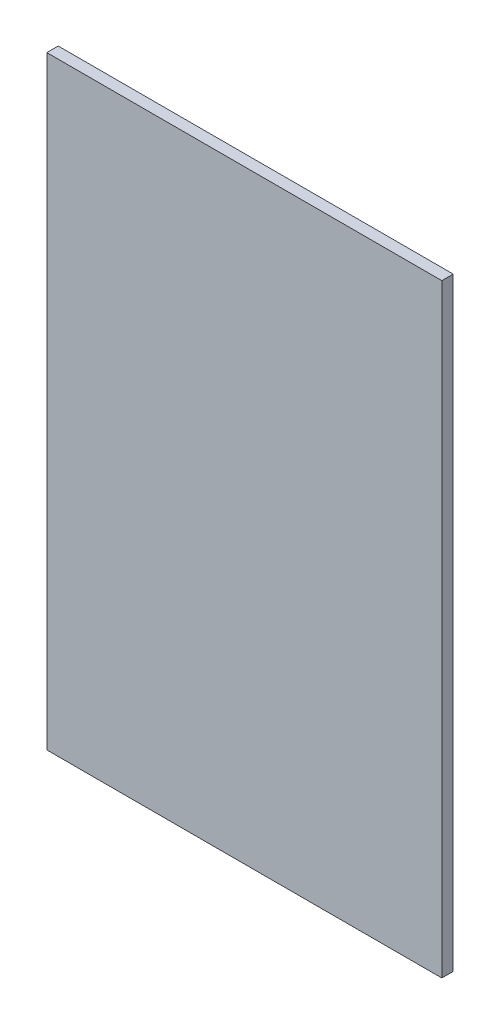
from build123d import *

# Parameters (mm, degrees)
ESQUISSE1_W        = 208
ESQUISSE1_H        = 318
BOSS_EXTRU_1_DEPTH = 6


with BuildPart() as part:
    # Esquisse1 → Boss.-Extru.1 (new body)
    with BuildSketch(Plane.XY):
        with Locations((65.929164598, 0)):
            Rectangle(ESQUISSE1_W, ESQUISSE1_H)
    extrude(amount=BOSS_EXTRU_1_DEPTH)


solid = part.part
